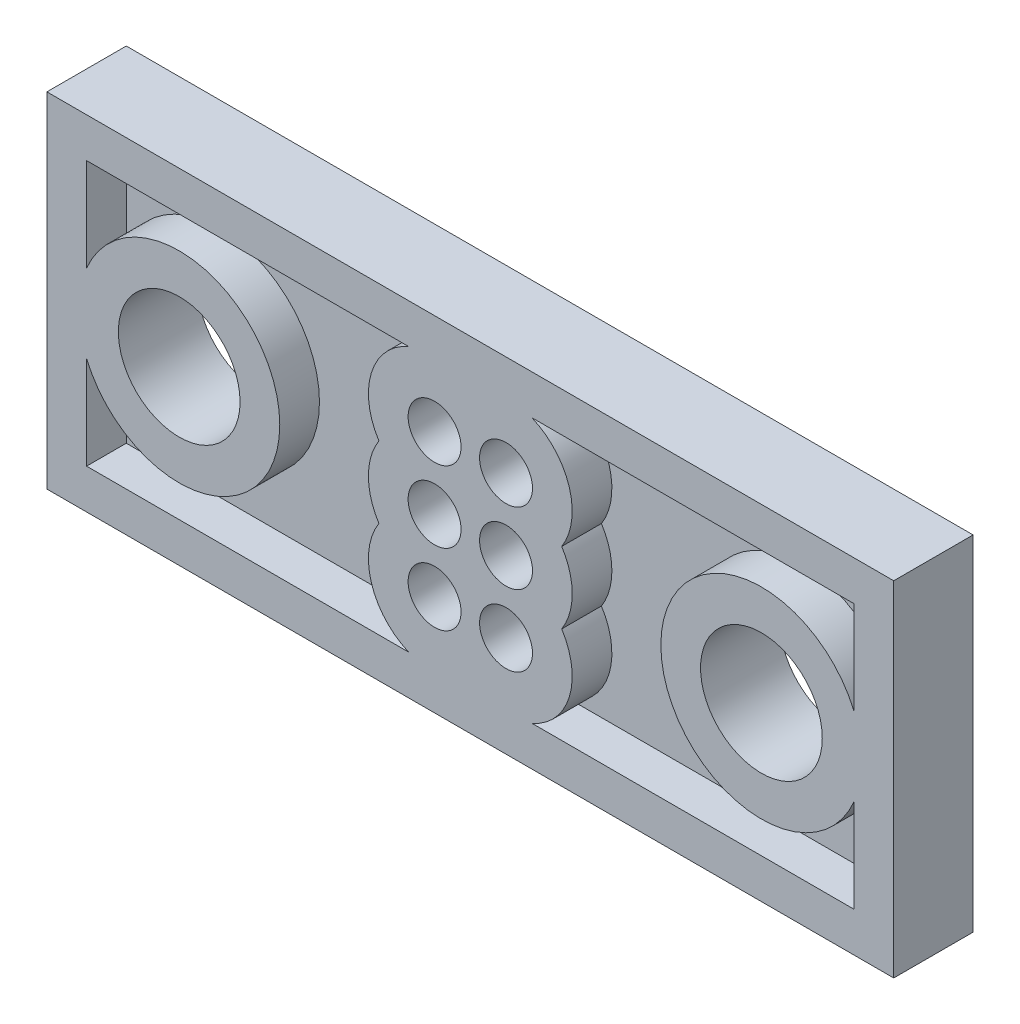
from build123d import *

# Parameters (mm, degrees)
ESQUISSE1_W             = 32
ESQUISSE1_H             = 13
ESQUISSE1_R             = 2.3
ESQUISSE1_R_2           = 1
BOSS_EXTRU_1_DEPTH      = 3
ENL_V_MAT_EXTRU_1_DEPTH = 1.5


with BuildPart() as part:
    # Esquisse1 → Boss.-Extru.1 (new body)
    with BuildSketch(Plane.XY):
        with Locations((16, 6.5)):
            Rectangle(ESQUISSE1_W, ESQUISSE1_H)
        with Locations((5, 6.5)):
            Circle(ESQUISSE1_R, mode=Mode.SUBTRACT)
        with Locations((27, 6.5)):
            Circle(ESQUISSE1_R, mode=Mode.SUBTRACT)
        with Locations((14.65, 9.2)):
            Circle(ESQUISSE1_R_2, mode=Mode.SUBTRACT)
        with Locations((17.35, 9.2)):
            Circle(ESQUISSE1_R_2, mode=Mode.SUBTRACT)
        with Locations((17.35, 6.5)):
            Circle(ESQUISSE1_R_2, mode=Mode.SUBTRACT)
        with Locations((14.65, 3.8)):
            Circle(ESQUISSE1_R_2, mode=Mode.SUBTRACT)
        with Locations((14.65, 6.5)):
            Circle(ESQUISSE1_R_2, mode=Mode.SUBTRACT)
        with Locations((17.35, 3.8)):
            Circle(ESQUISSE1_R_2, mode=Mode.SUBTRACT)
    extrude(amount=BOSS_EXTRU_1_DEPTH)

    # Esquisse2 → Enlèv. mat.-Extru.1 (cut)
    with BuildSketch(Plane.XY.offset(3)):
        with BuildLine():
            Line((1.5, 11.5), (13.670204103, 11.5))
            ThreePointArc((13.670204103, 11.5), (12.260789898, 9.935985793), (12.545837459, 7.85))
            ThreePointArc((12.545837459, 7.85), (12.15, 6.5), (12.545837459, 5.15))
            ThreePointArc((12.545837459, 5.15), (12.260789898, 3.064014207), (13.670204103, 1.5))
            Line((13.670204103, 1.5), (1.5, 1.5))
            Line((1.5, 1.5), (1.5, 5.020135141))
            ThreePointArc((1.5, 5.020135141), (8.8, 6.5), (1.5, 7.979864859))
            Line((1.5, 7.979864859), (1.5, 11.5))
        make_face()
        with BuildLine():
            Line((30.5, 1.5), (18.329795897, 1.5))
            ThreePointArc((18.329795897, 1.5), (19.739210102, 3.064014207), (19.454162541, 5.15))
            ThreePointArc((19.454162541, 5.15), (19.85, 6.5), (19.454162541, 7.85))
            ThreePointArc((19.454162541, 7.85), (19.739210102, 9.935985793), (18.329795897, 11.5))
            Line((18.329795897, 11.5), (30.5, 11.5))
            Line((30.5, 11.5), (30.5, 7.979864859))
            ThreePointArc((30.5, 7.979864859), (23.2, 6.5), (30.5, 5.020135141))
            Line((30.5, 5.020135141), (30.5, 1.5))
        make_face()
    extrude(amount=-ENL_V_MAT_EXTRU_1_DEPTH, mode=Mode.SUBTRACT)


solid = part.part
